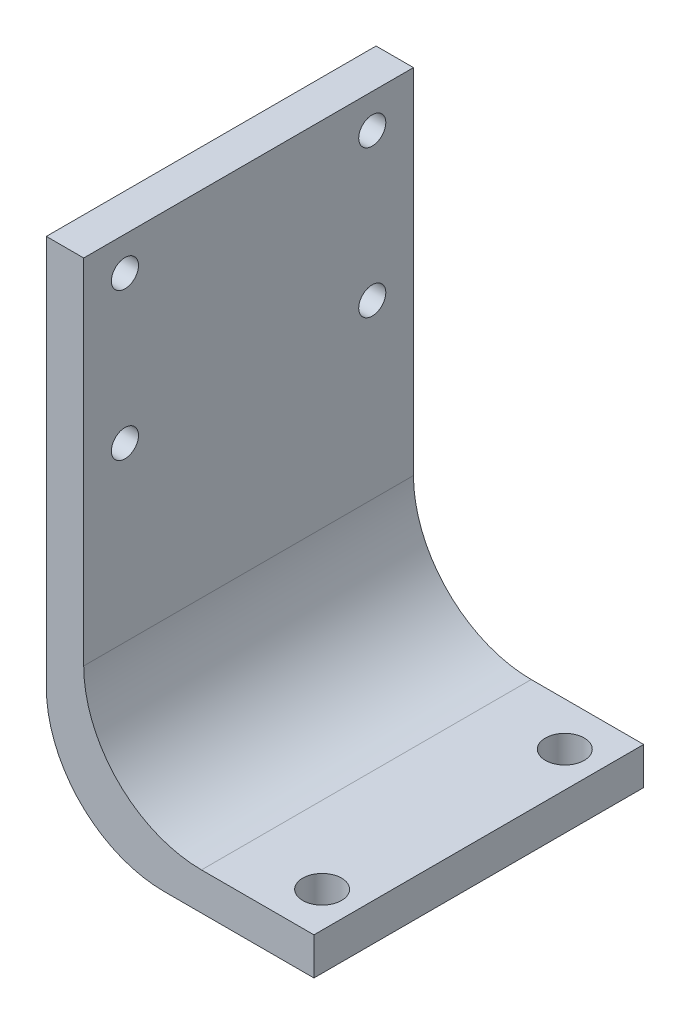
from build123d import *

# Parameters (mm, degrees)
SKETCH1_W           = 22.722789772
SKETCH1_H           = 28
SKETCH1_R           = 1.65
BOSS_EXTRUDE1_DEPTH = 3.175
SKETCH2_W           = 3.175
SKETCH2_H           = 28
BOSS_EXTRUDE2_DEPTH = 40
FILLET1_R           = 10
SKETCH3_R           = 1.15
CUT_EXTRUDE1_DEPTH  = 3.175


with BuildPart() as part:
    # Sketch1 → Boss-Extrude1 (new body)
    with BuildSketch(Plane(origin=(0, 0, 0), x_dir=(1, 0, 0), z_dir=(0, 1, 0))):
        Rectangle(SKETCH1_W, SKETCH1_H)
        with Locations((8.361394886, 10.30327082)):
            Circle(SKETCH1_R, mode=Mode.SUBTRACT)
        with Locations((8.361394886, -10.30327082)):
            Circle(SKETCH1_R, mode=Mode.SUBTRACT)
    extrude(amount=BOSS_EXTRUDE1_DEPTH)

    # Sketch2 → Boss-Extrude2 (add)
    with BuildSketch(Plane(origin=(0, 3.175, 0), x_dir=(1, 0, 0), z_dir=(0, 1, 0))):
        with Locations((-9.773894886, 0)):
            Rectangle(SKETCH2_W, SKETCH2_H)
    extrude(amount=BOSS_EXTRUDE2_DEPTH)

    # Fillet1
    fillet1_edges = [part.edges().sort_by_distance(p)[0] for p in [
        (-8.186394886, 3.175, 0),
        (-11.361394886, 0, 0),
    ]]
    fillet(fillet1_edges, radius=FILLET1_R)

    # Sketch3 → Cut-Extrude1 (cut)
    with BuildSketch(Plane.ZY.offset(11.361394886)):
        with Locations((10.5, 40.305754395)):
            Circle(SKETCH3_R)
        with Locations((10.5, 27.805754395)):
            Circle(SKETCH3_R)
        with Locations((-10.5, 40.305754395)):
            Circle(SKETCH3_R)
        with Locations((-10.5, 27.805754395)):
            Circle(SKETCH3_R)
    extrude(amount=-CUT_EXTRUDE1_DEPTH, mode=Mode.SUBTRACT)


solid = part.part
